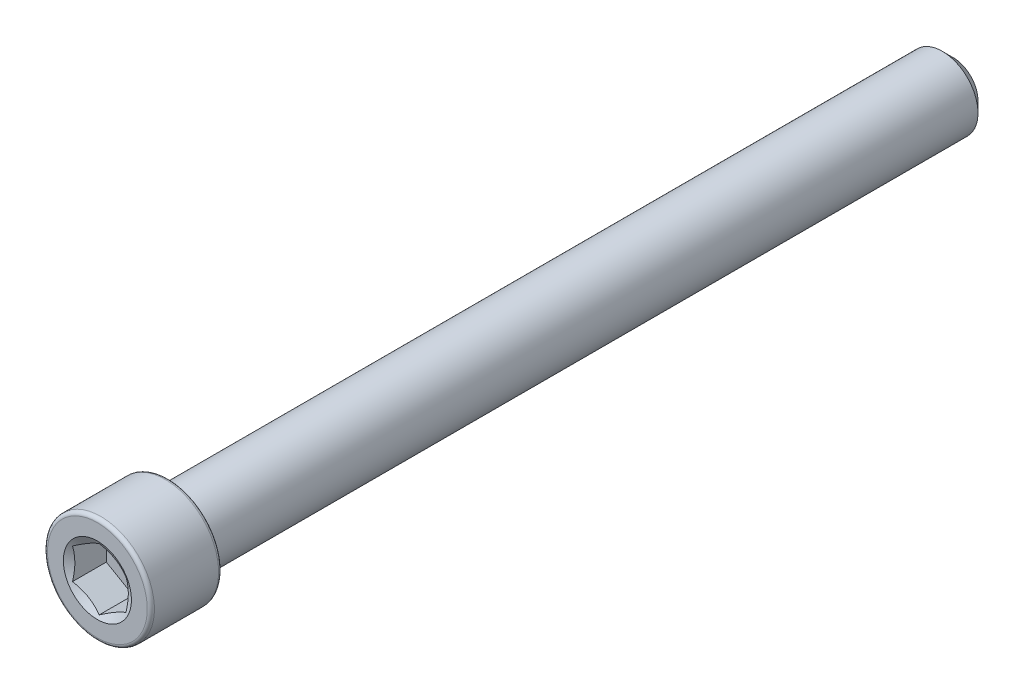
from build123d import *

# Parameters (mm, degrees)
CUT_EXTRUDE1_START = 38.1
CUT_EXTRUDE1_DEPTH = 3.175


with BuildPart() as part:
    # Sketch2 → Revolve1 (revolve)
    with BuildSketch(Plane(origin=(0, 0, 0), x_dir=(0, 0, -1), z_dir=(1, 0, 0)), mode=Mode.PRIVATE) as revolve1_sk:
        with BuildLine():
            Line((38.1, 0), (38.1, 2.2225))
            Line((38.1, 2.2225), (37.1475, 3.175))
            Line((37.1475, 3.175), (-31.75, 3.175))
            Line((-31.75, 3.175), (-31.75, 4.445))
            ThreePointArc((-31.75, 4.445), (-31.842993597, 4.669506403), (-32.0675, 4.7625))
            Line((-32.0675, 4.7625), (-37.7825, 4.7625))
            ThreePointArc((-37.7825, 4.7625), (-38.007006403, 4.669506403), (-38.1, 4.445))
            Line((-38.1, 4.445), (-38.1, 0))
            Line((-38.1, 0), (38.1, 0))
        make_face()
    revolve(revolve1_sk.sketch.rotate(Axis((0, 0, -38.1), (0, 0, 1)), 90), axis=Axis((0, 0, -38.1), (0, 0, 1)))

    # Sketch3 → Cut-Extrude1 (cut)
    with BuildSketch(Plane.XY.offset(CUT_EXTRUDE1_START)):
        Polygon((-2.38125, 1.374815329), (-2.38125, -1.374815329), (0, -2.749630657), (2.38125, -1.374815329), (2.38125, 1.374815329), (0, 2.749630657), align=None)
    extrude(amount=-CUT_EXTRUDE1_DEPTH, mode=Mode.SUBTRACT)

    # Cut-Extrude2 cone 1 section (through the dimple's axis) → Cut-Extrude2 (revolve, cut)
    with BuildSketch(Plane(origin=(0, 0, 38.1), x_dir=(0, -1, 0), z_dir=(1, 0, 0))):
        Polygon((0, 0), (3.032192214, 0), (0, 1.750636991), align=None)
    revolve(axis=Axis((0, 0, 38.1), (0, 0, -1)), mode=Mode.SUBTRACT)


solid = part.part
